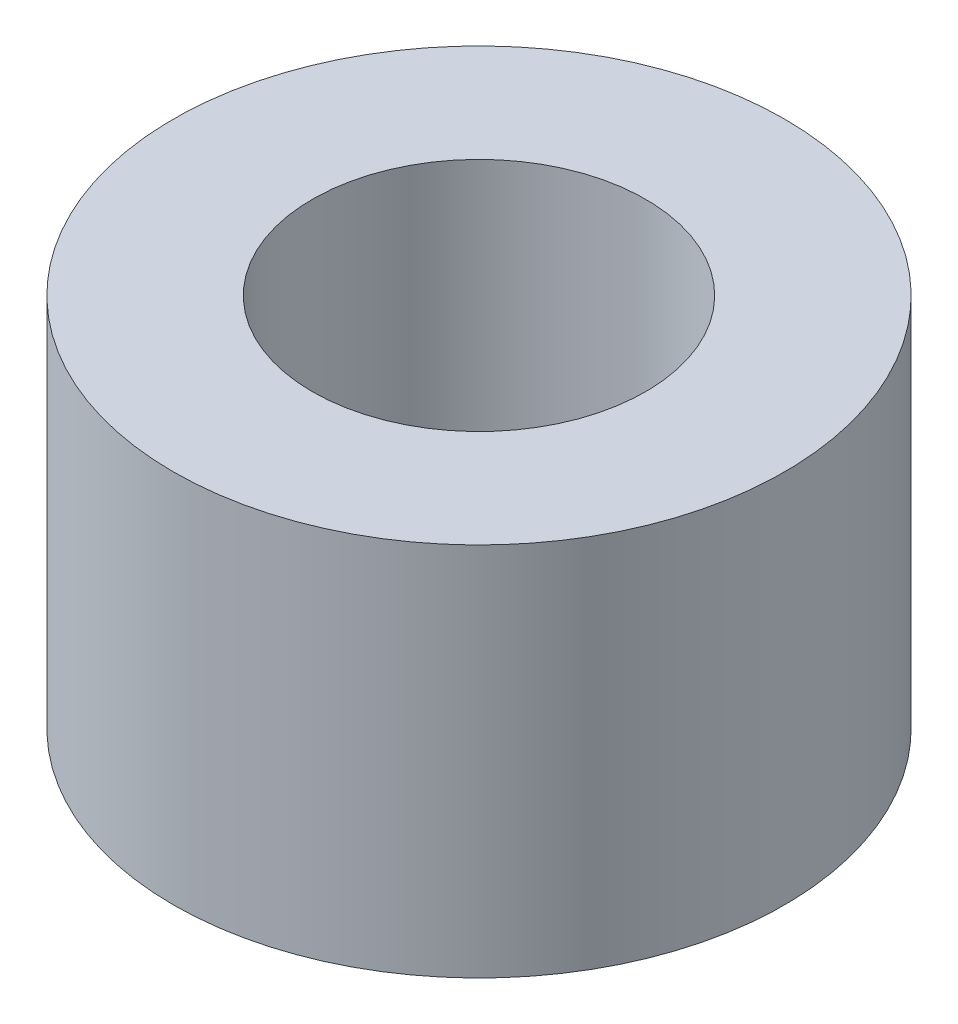
from build123d import *

# Parameters (mm, degrees)
SKETCH1_R           = 5.5
SKETCH1_R_2         = 3
BOSS_EXTRUDE1_DEPTH = 6.75


with BuildPart() as part:
    # Sketch1 → Boss-Extrude1 (new body)
    with BuildSketch(Plane(origin=(0, 0, 0), x_dir=(1, 0, 0), z_dir=(0, 1, 0))):
        Circle(SKETCH1_R)
        Circle(SKETCH1_R_2, mode=Mode.SUBTRACT)
    extrude(amount=BOSS_EXTRUDE1_DEPTH)


solid = part.part
